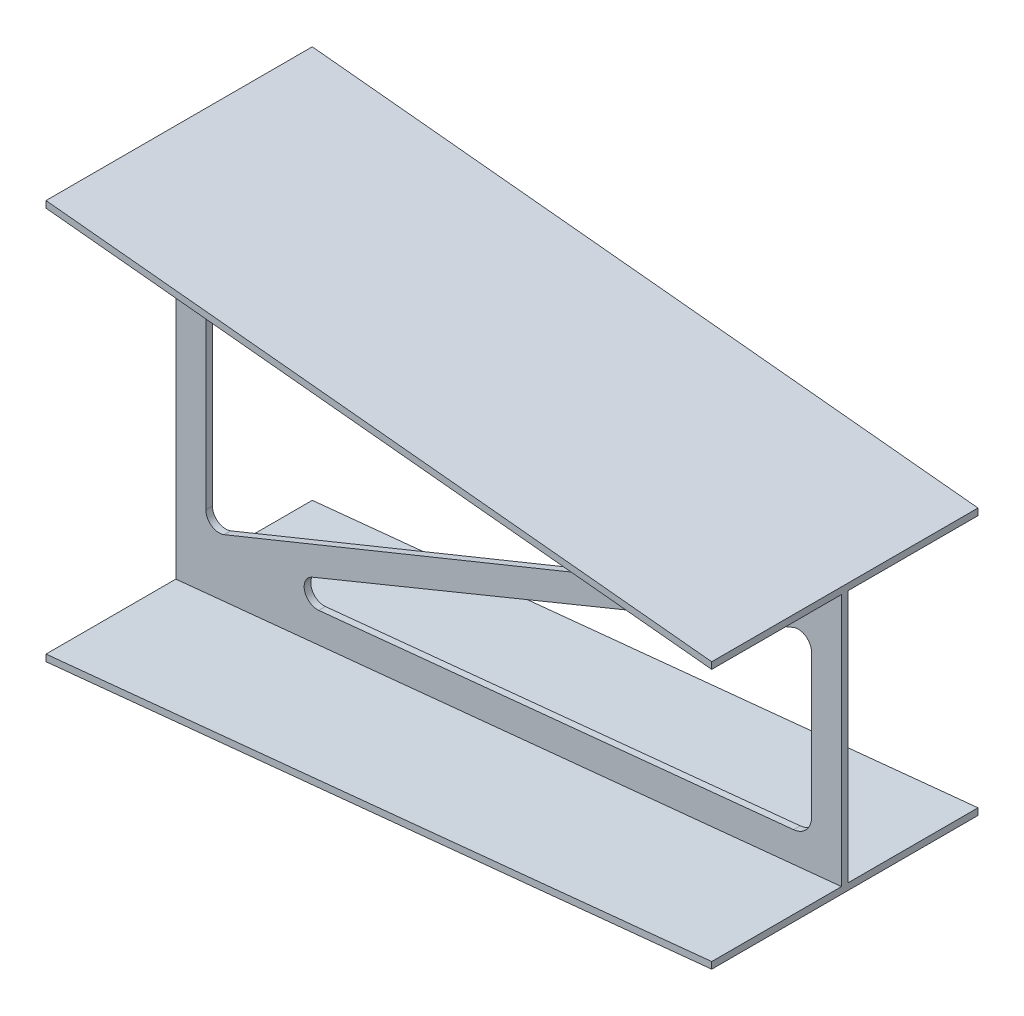
from build123d import *

# Parameters (mm, degrees)
CUT_EXTRUDE2_DEPTH = 1076.127215203


with BuildPart() as part:
    # Sketch1 → Loft4 section 0
    with BuildSketch(Plane(origin=(0, 0, 0), x_dir=(0, 0, -1), z_dir=(1, 0, 0))):
        Polygon((-205, 300), (195, 300), (195, 290), (0, 290), (0, -290), (195, -290), (195, -300), (-205, -300), (-205, -290), (-10, -290), (-10, 290), (-205, 290), align=None)
    # Sketch4 → Loft4 section 1
    with BuildSketch(Plane(origin=(1000, 0, -1000), x_dir=(0, 0, 1), z_dir=(-1, 0, 0))):
        Polygon((805, 200), (1205, 200), (1205, 190), (1010, 190), (1010, -190), (1205, -190), (1205, -200), (805, -200), (805, -190), (1000, -190), (1000, 190), (805, 190), align=None)
    loft()

    # 3DSketch1 → Cut-Extrude2 (cut, through all)
    with BuildSketch(Plane(origin=(955, -149.275559705, 0), x_dir=(-0.9193091385176674, 0.39353615823441734, 0), z_dir=(0, 0, 1))):
        with BuildLine():
            Line((23.771900268, 13.114838789), (651.375957176, 359.360866092))
            ThreePointArc((651.375957176, 359.360866092), (676.975392867, 353.930952286), (675.287892891, 327.816446442))
            Line((675.287892891, 327.816446442), (127.715549412, -228.2676011))
            ThreePointArc((127.715549412, -228.2676011), (109.754280938, -233.887743911), (95.078586754, -222.105674031))
            Line((95.078586754, -222.105674031), (10.684359853, -24.958900083))
            ThreePointArc((10.684359853, -24.958900083), (9.89296563, -3.400627082), (23.771900268, 13.114838789))
        make_face()
        with BuildLine():
            Line((825.502793093, 383.974217556), (976.828190217, 30.474754914))
            ThreePointArc((976.828190217, 30.474754914), (976.508407209, 6.141893153), (958.252169109, -9.948482636))
            Line((958.252169109, -9.948482636), (220.359519027, -242.09716271))
            ThreePointArc((220.359519027, -242.09716271), (197.283607657, -233.434785068), (200.139914384, -208.95262863))
            Line((200.139914384, -208.95262863), (792.899174378, 390.169926603))
            ThreePointArc((792.899174378, 390.169926603), (810.850417384, 395.751870528), (825.502793093, 383.974217556))
        make_face()
    extrude(amount=CUT_EXTRUDE2_DEPTH, mode=Mode.SUBTRACT)


solid = part.part
